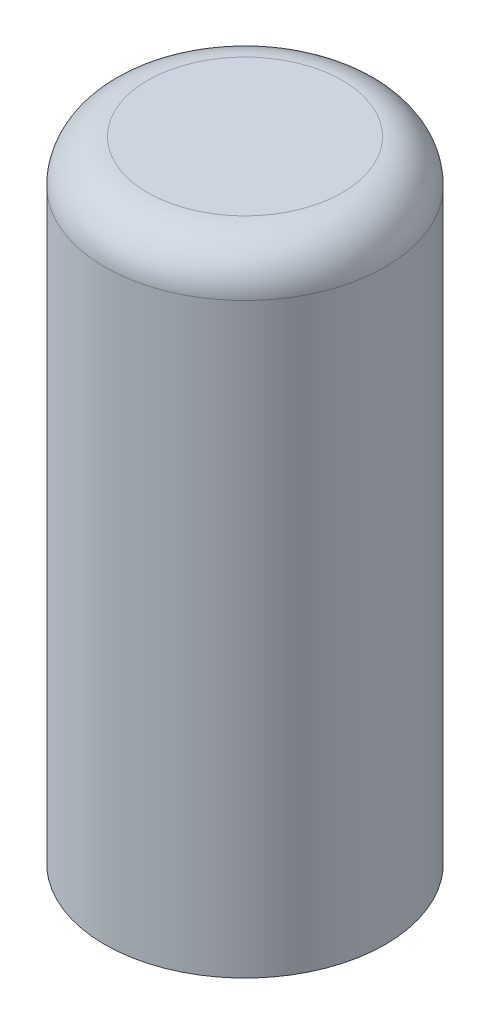
from build123d import *

# Parameters (mm, degrees)
SKETCH1_R           = 4.9
BOSS_EXTRUDE1_DEPTH = 22
FILLET1_R           = 1.5


with BuildPart() as part:
    # Sketch1 → Boss-Extrude1 (new body)
    with BuildSketch(Plane(origin=(0, 0, 0), x_dir=(1, 0, 0), z_dir=(0, 1, 0))):
        Circle(SKETCH1_R)
    extrude(amount=BOSS_EXTRUDE1_DEPTH)

    # Fillet1
    fillet1_edges = [part.edges().sort_by_distance(p)[0] for p in [
        (-4.9, 22, 0),
    ]]
    fillet(fillet1_edges, radius=FILLET1_R)


solid = part.part
